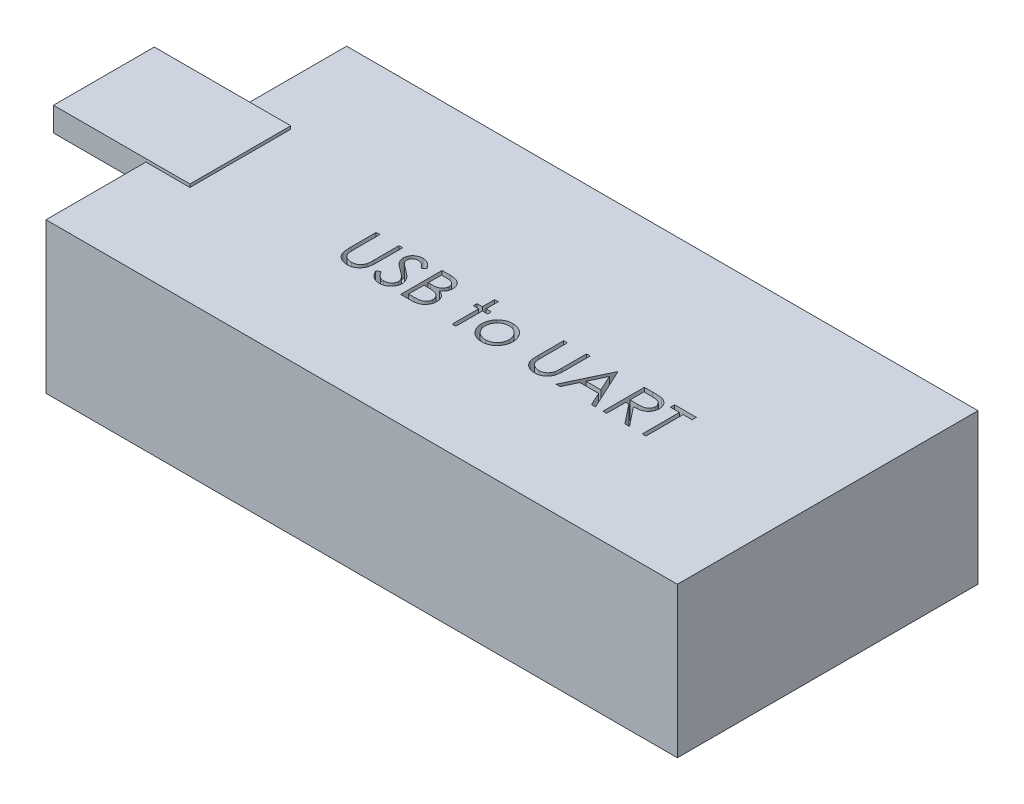
from build123d import *

# Parameters (mm, degrees)
SKETCH1_W           = 53.34
SKETCH1_H           = 25.4
BOSS_EXTRUDE1_DEPTH = 12.7
CUT_EXTRUDE1_DEPTH  = 1.524
SKETCH7_W           = 11.527903952
SKETCH7_H           = 8.5161628
BOSS_EXTRUDE4_DEPTH = 0.254
SKETCH7_3_W         = 11.527903952
SKETCH7_3_H         = 8.5161628
BOSS_EXTRUDE5_DEPTH = 1.778


with BuildPart() as part:
    # Sketch1 → Boss-Extrude1 (new body)
    with BuildSketch(Plane(origin=(0, 0, 0), x_dir=(1, 0, 0), z_dir=(0, 1, 0))):
        Rectangle(SKETCH1_W, SKETCH1_H)
    extrude(amount=BOSS_EXTRUDE1_DEPTH)

    # Sketch2 → Cut-Extrude1 (cut)
    # profile 1 of 9: a face of its own
    with BuildSketch(Plane(origin=(0, 12.7, 0), x_dir=(1, 0, 0), z_dir=(0, 1, 0))):
        with BuildLine():
            Line((-11.793928984, 0.317756753), (-11.47982642, 0.317756753))
            Line((-11.47982642, 0.317756753), (-11.47982642, -1.779298535))
            add(Edge.make_bspline(
                [(-11.47982642, -1.779298535), (-11.479873164, -1.808979271), (-11.479961869, -1.865303582), (-11.479369355, -1.945471882), (-11.477709987, -2.016744341), (-11.476663827, -2.079395689), (-11.474336494, -2.133138436), (-11.472438447, -2.178263747), (-11.46999789, -2.214557949), (-11.467064773, -2.235738875), (-11.465803984, -2.244843407)],
                knots=[0, 0, 0, 0, 1.528628734, 2.90083645, 4.128790002, 5.200304208, 6.127813768, 6.898992206, 7.526736466, 8, 8, 8, 8], degree=3))
            add(Edge.make_bspline(
                [(-11.465803984, -2.244843407), (-11.460626526, -2.27769017), (-11.450563339, -2.341532899), (-11.424916962, -2.432441181), (-11.389099461, -2.514372639), (-11.346656418, -2.589883931), (-11.290723806, -2.656873291), (-11.223720271, -2.718584943), (-11.142542503, -2.772556748), (-11.052281897, -2.82190756), (-10.954996659, -2.861572642), (-10.855585393, -2.891566007), (-10.755542414, -2.909844906), (-10.688566249, -2.911961445), (-10.65530719, -2.913012477)],
                knots=[0, 0, 0, 0, 1.035780045, 2.013197591, 2.933192213, 3.817615948, 4.702609284, 5.640816605, 6.646850145, 7.73207398, 8.84249596, 9.914020372, 10.964143139, 12, 12, 12, 12], degree=3))
            add(Edge.make_bspline(
                [(-10.65530719, -2.913012477), (-10.626753449, -2.911938627), (-10.569810887, -2.909797129), (-10.485204457, -2.896535698), (-10.402804348, -2.872635132), (-10.322203668, -2.841795374), (-10.246652684, -2.801047783), (-10.176109242, -2.753976943), (-10.113145307, -2.698766067), (-10.05568731, -2.637665722), (-10.005652374, -2.568725923), (-9.962281232, -2.493447784), (-9.926755302, -2.410698438), (-9.909211778, -2.352544015), (-9.900199017, -2.322667926)],
                knots=[0, 0, 0, 0, 0.994687771, 1.983630487, 2.973142513, 3.978332533, 4.983357753, 5.956394766, 6.925816176, 7.893390482, 8.871859704, 9.88551698, 10.913711441, 12, 12, 12, 12], degree=3))
            add(Edge.make_bspline(
                [(-9.900199017, -2.322667926), (-9.897198891, -2.310319352), (-9.890513403, -2.282801752), (-9.884266358, -2.236280461), (-9.877759833, -2.181391097), (-9.873245263, -2.117739284), (-9.868844042, -2.045538312), (-9.866210969, -1.964412054), (-9.864993936, -1.874655093), (-9.864631256, -1.812017932), (-9.864441805, -1.779298535)],
                knots=[0, 0, 0, 0, 0.558680831, 1.244966039, 2.062412453, 2.990489873, 4.051219941, 5.244515665, 6.560634259, 8, 8, 8, 8], degree=3))
            Line((-9.864441805, -1.779298535), (-9.864441805, 0.317756753))
            Line((-9.864441805, 0.317756753), (-9.550339241, 0.317756753))
            Line((-9.550339241, 0.317756753), (-9.550339241, -1.796125458))
            add(Edge.make_bspline(
                [(-9.550339241, -1.796125458), (-9.550593361, -1.834223837), (-9.551089293, -1.90857514), (-9.555389869, -2.017526499), (-9.562246869, -2.12087948), (-9.571934957, -2.218647977), (-9.58477196, -2.310482136), (-9.599047181, -2.397186904), (-9.617226714, -2.478139897), (-9.638460115, -2.553972315), (-9.662733663, -2.626157828), (-9.694174811, -2.694666443), (-9.729599311, -2.761580842), (-9.771613964, -2.825888951), (-9.818825347, -2.887875504), (-9.872277027, -2.947164579), (-9.930201188, -3.004703626), (-9.993560748, -3.059016692), (-10.061311273, -3.108825369), (-10.133251231, -3.15262314), (-10.208828001, -3.189646757), (-10.287845127, -3.220122682), (-10.37033633, -3.243037281), (-10.456303689, -3.260112436), (-10.545942883, -3.269814734), (-10.606907539, -3.271256664), (-10.637779145, -3.271986836)],
                knots=[0, 0, 0, 0, 1.316592851, 2.569410997, 3.76748051, 4.895814652, 5.963796859, 6.97159953, 7.931736103, 8.829262218, 9.692595152, 10.560224239, 11.431080259, 12.30701507, 13.211635791, 14.121146779, 15.063487852, 16.031507147, 17.00238618, 17.966455255, 18.938106653, 19.907068911, 20.888905087, 21.893141452, 22.933117798, 24, 24, 24, 24], degree=3))
            add(Edge.make_bspline(
                [(-10.637779145, -3.271986836), (-10.671448247, -3.271202071), (-10.737506906, -3.269662364), (-10.834844973, -3.260839614), (-10.92815917, -3.24422122), (-11.018435047, -3.223061276), (-11.104443544, -3.193877539), (-11.187336988, -3.159779414), (-11.265695669, -3.117902154), (-11.340790798, -3.071308761), (-11.410615554, -3.018884123), (-11.474712957, -2.961743949), (-11.533188828, -2.900803571), (-11.585057524, -2.835403205), (-11.631178409, -2.766051498), (-11.670908622, -2.692552259), (-11.705021866, -2.614933943), (-11.722628433, -2.560980742), (-11.731529145, -2.533705586)],
                knots=[0, 0, 0, 0, 1.13879206, 2.234305948, 3.301075583, 4.341971843, 5.366689343, 6.369221514, 7.369726634, 8.367512178, 9.355451585, 10.318319045, 11.268648973, 12.207971039, 13.137398894, 14.081662264, 15.030215811, 16, 16, 16, 16], degree=3))
            add(Edge.make_bspline(
                [(-11.731529145, -2.533705586), (-11.736706303, -2.515073012), (-11.747935674, -2.474658543), (-11.759960972, -2.407772054), (-11.770070054, -2.330757137), (-11.779575612, -2.243608518), (-11.78518457, -2.146258652), (-11.790102008, -2.038749736), (-11.793963627, -1.920951774), (-11.793940855, -1.838897259), (-11.793928984, -1.796125458)],
                knots=[0, 0, 0, 0, 0.625038921, 1.35572334, 2.194682327, 3.136881307, 4.189498639, 5.346923369, 6.617055217, 8, 8, 8, 8], degree=3))
            Line((-11.793928984, -1.796125458), (-11.793928984, 0.317756753))
        make_face()
    # profile 2 of 9: a face of its own
    with BuildSketch(Plane(origin=(0, 12.7, 0), x_dir=(1, 0, 0), z_dir=(0, 1, 0))):
        with BuildLine():
            Line((-9.011877702, -2.507062958), (-8.716004305, -2.329679144))
            add(Edge.make_bspline(
                [(-8.716004305, -2.329679144), (-8.688486068, -2.375743529), (-8.635762187, -2.464001113), (-8.547810828, -2.583259153), (-8.456677917, -2.68462131), (-8.361688583, -2.767497918), (-8.263422635, -2.832746804), (-8.161238581, -2.878949036), (-8.055480771, -2.907765011), (-7.983506949, -2.911265098), (-7.947574818, -2.913012477)],
                knots=[0, 0, 0, 0, 1.272034388, 2.437168799, 3.508375237, 4.49857839, 5.41946034, 6.295179144, 7.148887113, 8, 8, 8, 8], degree=3))
            add(Edge.make_bspline(
                [(-7.947574818, -2.913012477), (-7.916887957, -2.912157805), (-7.856051184, -2.910463415), (-7.766488941, -2.894182612), (-7.679507139, -2.869170484), (-7.596898501, -2.833349552), (-7.519802887, -2.790011066), (-7.452196191, -2.737664889), (-7.393750078, -2.679058683), (-7.345940964, -2.613676028), (-7.309260928, -2.54335888), (-7.28106886, -2.471182929), (-7.265423786, -2.39601436), (-7.263067033, -2.345403897), (-7.261877702, -2.319863439)],
                knots=[0, 0, 0, 0, 1.095163259, 2.171163733, 3.241058638, 4.321873601, 5.38011039, 6.391990106, 7.366004449, 8.327778327, 9.272591725, 10.192022065, 11.087607919, 12, 12, 12, 12], degree=3))
            add(Edge.make_bspline(
                [(-7.261877702, -2.319863439), (-7.263352013, -2.290722589), (-7.266349071, -2.2314835), (-7.291680551, -2.144083847), (-7.331529798, -2.057591277), (-7.368292442, -2.004090011), (-7.387378504, -1.976313759)],
                knots=[0, 0, 0, 0, 0.938893495, 1.908633276, 2.914225137, 4, 4, 4, 4], degree=3))
            add(Edge.make_bspline(
                [(-7.387378504, -1.976313759), (-7.403049118, -1.956266936), (-7.435947612, -1.914181137), (-7.492505125, -1.851535902), (-7.558871239, -1.786917483), (-7.632774794, -1.717858426), (-7.716907883, -1.647570629), (-7.808635397, -1.572702351), (-7.910299256, -1.496100774), (-7.981598753, -1.444728209), (-8.018388119, -1.418220811)],
                knots=[0, 0, 0, 0, 0.722233717, 1.516239348, 2.393582979, 3.351407094, 4.387010283, 5.505090956, 6.712668013, 8, 8, 8, 8], degree=3))
            add(Edge.make_bspline(
                [(-8.018388119, -1.418220811), (-8.055212115, -1.391992223), (-8.125616792, -1.341845161), (-8.224075374, -1.267420877), (-8.312119837, -1.199377007), (-8.389358854, -1.137072995), (-8.455758451, -1.08050039), (-8.511841862, -1.030202451), (-8.556180419, -0.98481889), (-8.580835999, -0.955377549), (-8.591905747, -0.942159112)],
                knots=[0, 0, 0, 0, 1.452282411, 2.77665338, 3.964542531, 5.026858415, 5.96415736, 6.766646006, 7.446254459, 8, 8, 8, 8], degree=3))
            add(Edge.make_bspline(
                [(-8.591905747, -0.942159112), (-8.607378293, -0.921558075), (-8.637807129, -0.881043371), (-8.677973135, -0.817718514), (-8.712112297, -0.752895248), (-8.73887463, -0.686399384), (-8.761410848, -0.619164455), (-8.776568779, -0.550313209), (-8.786060176, -0.480154591), (-8.787032163, -0.43294109), (-8.787518728, -0.409306548)],
                knots=[0, 0, 0, 0, 1.068054152, 2.10047183, 3.106115577, 4.101338837, 5.06977816, 6.043150881, 7.020423561, 8, 8, 8, 8], degree=3))
            add(Edge.make_bspline(
                [(-8.787518728, -0.409306548), (-8.786213519, -0.372276773), (-8.783630999, -0.29900871), (-8.761790482, -0.191977879), (-8.727317588, -0.089791462), (-8.6790227, 0.006538872), (-8.616765347, 0.094504853), (-8.544719373, 0.17511834), (-8.458907887, 0.242886922), (-8.364755263, 0.30209898), (-8.261698891, 0.348444906), (-8.153707988, 0.383405886), (-8.040610916, 0.403215143), (-7.964007781, 0.406057908), (-7.92513892, 0.407500343)],
                knots=[0, 0, 0, 0, 1.005424448, 1.989358655, 2.955360095, 3.929531133, 4.905563448, 5.876582895, 6.856512386, 7.866279853, 8.892233794, 9.918561126, 10.94386622, 12, 12, 12, 12], degree=3))
            add(Edge.make_bspline(
                [(-7.92513892, 0.407500343), (-7.88389482, 0.406077792), (-7.801873468, 0.403248791), (-7.681224253, 0.378651259), (-7.565063536, 0.337950587), (-7.471620272, 0.291761929), (-7.39848751, 0.245630514), (-7.342714777, 0.203610689), (-7.286197327, 0.155235581), (-7.228479272, 0.100376335), (-7.170538612, 0.038529584), (-7.11151516, -0.029881105), (-7.051270891, -0.104437661), (-7.012515031, -0.157662162), (-6.992646933, -0.184947573)],
                knots=[0, 0, 0, 0, 1.286793592, 2.559021753, 3.825965368, 5.121522368, 5.803751409, 6.523245864, 7.299691795, 8.125521123, 9.008227632, 9.944561021, 10.946284179, 12, 12, 12, 12], degree=3))
            Line((-6.992646933, -0.184947573), (-7.27660126, -0.400191964))
            add(Edge.make_bspline(
                [(-7.27660126, -0.400191964), (-7.293747193, -0.378103274), (-7.32676625, -0.335565621), (-7.376895737, -0.275994305), (-7.424144384, -0.221577826), (-7.470694784, -0.174312698), (-7.514088416, -0.131610564), (-7.556205458, -0.095050808), (-7.596439809, -0.064275212), (-7.64715672, -0.031431652), (-7.710874438, 0.001124851), (-7.790858974, 0.02867393), (-7.874445249, 0.045228991), (-7.931374881, 0.047417879), (-7.96019501, 0.048525984)],
                knots=[0, 0, 0, 0, 1.181633172, 2.275549214, 3.290209073, 4.226197932, 5.078386478, 5.862611352, 6.581680152, 7.217281963, 8.414376989, 9.595101626, 10.782541182, 12, 12, 12, 12], degree=3))
            add(Edge.make_bspline(
                [(-7.96019501, 0.048525984), (-7.996351533, 0.047314284), (-8.06607598, 0.044977635), (-8.165066216, 0.01945765), (-8.254160141, -0.020724211), (-8.330712706, -0.077039189), (-8.394449683, -0.143760181), (-8.440555142, -0.220539036), (-8.468305307, -0.305321439), (-8.471691586, -0.364463095), (-8.473416164, -0.39458299)],
                knots=[0, 0, 0, 0, 1.14458467, 2.207223713, 3.21896685, 4.227309161, 5.202851033, 6.127160689, 7.046193047, 8, 8, 8, 8], degree=3))
            add(Edge.make_bspline(
                [(-8.473416164, -0.39458299), (-8.473023037, -0.413334469), (-8.472236141, -0.450868088), (-8.461261344, -0.50631951), (-8.447162015, -0.561630849), (-8.424819383, -0.616553432), (-8.393974079, -0.672047791), (-8.353468903, -0.729069529), (-8.302455591, -0.788121238), (-8.263378579, -0.826528611), (-8.242747093, -0.846806548)],
                knots=[0, 0, 0, 0, 0.858281714, 1.717966888, 2.583508476, 3.4729293, 4.427298488, 5.488583878, 6.674047936, 8, 8, 8, 8], degree=3))
            add(Edge.make_bspline(
                [(-8.242747093, -0.846806548), (-8.235085721, -0.853643574), (-8.216884054, -0.869886782), (-8.183608128, -0.896479063), (-8.13966533, -0.929281835), (-8.086203129, -0.969869151), (-8.022235767, -1.016950614), (-7.947756211, -1.069924226), (-7.863594678, -1.130509685), (-7.803872762, -1.172867225), (-7.772294369, -1.19526408)],
                knots=[0, 0, 0, 0, 0.420754252, 0.999615792, 1.744751191, 2.668019286, 3.750313428, 4.999500688, 6.413464383, 8, 8, 8, 8], degree=3))
            add(Edge.make_bspline(
                [(-7.772294369, -1.19526408), (-7.734308456, -1.222905439), (-7.660753999, -1.276429101), (-7.556096419, -1.356844781), (-7.461202611, -1.43549255), (-7.375739408, -1.511870157), (-7.298862499, -1.58539825), (-7.231424779, -1.65696143), (-7.172739098, -1.726047003), (-7.10955988, -1.814619579), (-7.04500206, -1.923400663), (-6.989560553, -2.056678901), (-6.954602205, -2.190475222), (-6.95003069, -2.280402058), (-6.947775138, -2.324771291)],
                knots=[0, 0, 0, 0, 1.163667725, 2.253281268, 3.268753668, 4.215851969, 5.092017293, 5.902905408, 6.650798638, 7.335211899, 8.59617414, 9.77448103, 10.901945474, 12, 12, 12, 12], degree=3))
            add(Edge.make_bspline(
                [(-6.947775138, -2.324771291), (-6.948432276, -2.356149657), (-6.949733791, -2.41829704), (-6.964694705, -2.509552117), (-6.98661437, -2.598182987), (-7.019651604, -2.683094099), (-7.059974763, -2.765838862), (-7.111141011, -2.844246762), (-7.170448695, -2.920053161), (-7.23848246, -2.991236652), (-7.312928362, -3.056582848), (-7.391612057, -3.11471191), (-7.47466233, -3.163180233), (-7.561628647, -3.202731075), (-7.652530983, -3.233664593), (-7.747338767, -3.256077462), (-7.846208279, -3.269833173), (-7.91340876, -3.271260934), (-7.947574818, -3.271986836)],
                knots=[0, 0, 0, 0, 0.983748083, 1.948392443, 2.894712957, 3.844097841, 4.80183111, 5.778335162, 6.776009319, 7.81870978, 8.863265674, 9.881300176, 10.883814829, 11.87499822, 12.874611388, 13.892143829, 14.928324115, 16, 16, 16, 16], degree=3))
            add(Edge.make_bspline(
                [(-7.947574818, -3.271986836), (-7.974010161, -3.271475655), (-8.026547921, -3.270459729), (-8.104257403, -3.261478449), (-8.180396992, -3.248771345), (-8.254011274, -3.228597275), (-8.326048686, -3.204120298), (-8.39619592, -3.173981966), (-8.464486974, -3.137864764), (-8.531304557, -3.09656974), (-8.596478731, -3.048511995), (-8.659398199, -2.992538499), (-8.722127385, -2.930192994), (-8.782814781, -2.85978243), (-8.842687925, -2.782444347), (-8.900566335, -2.697455164), (-8.957648053, -2.60527781), (-8.993463521, -2.540412725), (-9.011877702, -2.507062958)],
                knots=[0, 0, 0, 0, 0.915332311, 1.819136955, 2.706846663, 3.586547465, 4.459518054, 5.340707479, 6.227863349, 7.133153174, 8.059268498, 9.028702269, 10.047606654, 11.120612155, 12.245963614, 13.433783089, 14.680604001, 16, 16, 16, 16], degree=3))
        make_face()
    # profile 3 of 9: a face of its own
    with BuildSketch(Plane(origin=(0, 12.7, 0), x_dir=(1, 0, 0), z_dir=(0, 1, 0))):
        with BuildLine():
            Line((-6.22982642, 0.317756753), (-5.546933792, 0.317756753))
            add(Edge.make_bspline(
                [(-5.546933792, 0.317756753), (-5.513505314, 0.317581003), (-5.448712604, 0.317240355), (-5.354493162, 0.311957224), (-5.266244351, 0.304753554), (-5.183940579, 0.293323461), (-5.107619876, 0.279531684), (-5.037052239, 0.262829868), (-4.972462067, 0.242803254), (-4.89534933, 0.210956973), (-4.80742867, 0.163633805), (-4.712230277, 0.09370524), (-4.630826038, 0.008172777), (-4.56063972, -0.088309879), (-4.504838601, -0.194445651), (-4.464469303, -0.307704839), (-4.438911428, -0.426626581), (-4.436282994, -0.508269759), (-4.434954625, -0.549530907)],
                knots=[0, 0, 0, 0, 1.001505555, 1.941167018, 2.826882275, 3.653841531, 4.429895133, 5.150066043, 5.825578002, 6.45369114, 7.647487171, 8.808567382, 9.977351308, 11.170798116, 12.373658725, 13.556498008, 14.765093433, 16, 16, 16, 16], degree=3))
            add(Edge.make_bspline(
                [(-4.434954625, -0.549530907), (-4.436047844, -0.588183462), (-4.438196121, -0.664139379), (-4.458738881, -0.775233489), (-4.490899549, -0.880984708), (-4.535604798, -0.981007093), (-4.593706794, -1.073040706), (-4.662565113, -1.157827972), (-4.745641916, -1.231779029), (-4.807885156, -1.273121932), (-4.839501901, -1.294122253)],
                knots=[0, 0, 0, 0, 1.044552857, 2.05264487, 3.044412934, 4.028983338, 5.005914585, 5.980388656, 6.974128949, 8, 8, 8, 8], degree=3))
            add(Edge.make_bspline(
                [(-4.839501901, -1.294122253), (-4.799741474, -1.309387252), (-4.723669926, -1.338592976), (-4.618983914, -1.39022844), (-4.528789069, -1.446390551), (-4.452391923, -1.507722401), (-4.387054268, -1.573831212), (-4.330001326, -1.645686326), (-4.281319952, -1.724225084), (-4.239607029, -1.808628619), (-4.207058272, -1.898035087), (-4.182682368, -1.991605864), (-4.168714919, -2.089005419), (-4.166727278, -2.155290798), (-4.165723856, -2.188753663)],
                knots=[0, 0, 0, 0, 1.27268992, 2.434971085, 3.483601985, 4.442670788, 5.356604649, 6.2567628, 7.179492994, 8.113709626, 9.066344395, 10.018646069, 10.999752585, 12, 12, 12, 12], degree=3))
            add(Edge.make_bspline(
                [(-4.165723856, -2.188753663), (-4.166700702, -2.222920535), (-4.168622674, -2.290144813), (-4.182802646, -2.388899948), (-4.206811753, -2.483274895), (-4.239882899, -2.573880077), (-4.283045214, -2.660540212), (-4.335573178, -2.743353476), (-4.398204742, -2.821487806), (-4.468267611, -2.895811429), (-4.547529756, -2.962639217), (-4.633045511, -3.022154923), (-4.725891831, -3.071100986), (-4.824543825, -3.112217007), (-4.930108141, -3.143624206), (-5.042110749, -3.165596779), (-5.16045505, -3.180401816), (-5.241664802, -3.181619021), (-5.283311997, -3.182243247)],
                knots=[0, 0, 0, 0, 0.978564426, 1.925352924, 2.850884081, 3.763762016, 4.682927383, 5.618979971, 6.567305752, 7.547517671, 8.540179244, 9.531824382, 10.526200242, 11.540722885, 12.589160233, 13.674978461, 14.80764778, 16, 16, 16, 16], degree=3))
            Line((-5.283311997, -3.182243247), (-6.22982642, -3.182243247))
            Line((-6.22982642, -3.182243247), (-6.22982642, 0.317756753))
        make_face()
        with BuildLine():
            Line((-5.915723856, -0.041217606), (-5.915723856, -1.163012477))
            Line((-5.915723856, -1.163012477), (-5.704686196, -1.163012477))
            add(Edge.make_bspline(
                [(-5.704686196, -1.163012477), (-5.673837401, -1.162612554), (-5.614231241, -1.161839822), (-5.527911345, -1.159626304), (-5.447786327, -1.153428261), (-5.373994494, -1.147231999), (-5.30665205, -1.137157411), (-5.245908188, -1.125165288), (-5.190809591, -1.112482383), (-5.127270046, -1.090912896), (-5.055197097, -1.059035221), (-4.978363993, -1.009563385), (-4.910629523, -0.950639032), (-4.853432336, -0.88264807), (-4.806620865, -0.807781884), (-4.77410715, -0.727235004), (-4.752059866, -0.643014872), (-4.750068334, -0.585196619), (-4.74905719, -0.555841003)],
                knots=[0, 0, 0, 0, 1.156816544, 2.235205308, 3.236616184, 4.169592532, 5.011045266, 5.787822928, 6.49130361, 7.128639758, 8.301311294, 9.436451833, 10.541879658, 11.654887649, 12.756523258, 13.837046038, 14.901820046, 16, 16, 16, 16], degree=3))
            add(Edge.make_bspline(
                [(-4.74905719, -0.555841003), (-4.74958337, -0.536415231), (-4.75061553, -0.498309459), (-4.759068832, -0.442760105), (-4.773436407, -0.390516353), (-4.7918907, -0.340862242), (-4.817679389, -0.295350392), (-4.848042852, -0.252407196), (-4.884728542, -0.213495078), (-4.926485855, -0.17712558), (-4.974494478, -0.144881052), (-5.02872577, -0.116640289), (-5.089913447, -0.093899512), (-5.157026302, -0.073983359), (-5.231097389, -0.059995066), (-5.311271943, -0.048341678), (-5.398206662, -0.042408936), (-5.458351764, -0.041623573), (-5.489441805, -0.041217606)],
                knots=[0, 0, 0, 0, 0.91205012, 1.789085906, 2.630437955, 3.453916878, 4.269457761, 5.079663411, 5.91843418, 6.774407191, 7.675494373, 8.627863946, 9.638891023, 10.736472738, 11.911756761, 13.175263542, 14.539845004, 16, 16, 16, 16], degree=3))
            Line((-5.489441805, -0.041217606), (-5.915723856, -0.041217606))
        make_face(mode=Mode.SUBTRACT)
        with BuildLine():
            Line((-5.915723856, -1.521986836), (-5.915723856, -2.823268888))
            Line((-5.915723856, -2.823268888), (-5.468408151, -2.823268888))
            add(Edge.make_bspline(
                [(-5.468408151, -2.823268888), (-5.436389225, -2.82288514), (-5.374676967, -2.822145518), (-5.285575737, -2.819730963), (-5.202992633, -2.814238687), (-5.127304497, -2.805592838), (-5.057694044, -2.796214389), (-4.994996341, -2.783603108), (-4.938703148, -2.769154147), (-4.87342884, -2.746819975), (-4.799925332, -2.712123504), (-4.720714475, -2.659809278), (-4.650288257, -2.59748597), (-4.590482998, -2.525355056), (-4.54147001, -2.446923729), (-4.505814554, -2.363778379), (-4.483823698, -2.277292851), (-4.481161528, -2.218326139), (-4.47982642, -2.188753663)],
                knots=[0, 0, 0, 0, 1.160039823, 2.235823828, 3.228722157, 4.157150951, 4.99529583, 5.772374946, 6.472645482, 7.099169577, 8.269452708, 9.405989375, 10.527446681, 11.663510218, 12.788923519, 13.866172445, 14.929861265, 16, 16, 16, 16], degree=3))
            add(Edge.make_bspline(
                [(-4.47982642, -2.188753663), (-4.480102525, -2.170260323), (-4.48065028, -2.133571941), (-4.488910895, -2.079656122), (-4.500924764, -2.027430248), (-4.516456198, -1.976752508), (-4.539075665, -1.928539132), (-4.56548221, -1.881836572), (-4.596443612, -1.836583093), (-4.644687778, -1.779370839), (-4.714859763, -1.713453826), (-4.814566538, -1.648916324), (-4.927938836, -1.596868517), (-5.010166329, -1.574769041), (-5.052642927, -1.563353022)],
                knots=[0, 0, 0, 0, 0.723448775, 1.435228256, 2.130040452, 2.821711965, 3.505591119, 4.210454504, 4.921174351, 5.648778258, 7.137944449, 8.670945889, 10.280296675, 12, 12, 12, 12], degree=3))
            add(Edge.make_bspline(
                [(-5.052642927, -1.563353022), (-5.069672023, -1.559897938), (-5.106594615, -1.552406604), (-5.166802195, -1.5444989), (-5.235538064, -1.53745384), (-5.312960942, -1.532242683), (-5.399168783, -1.526856139), (-5.494345701, -1.524761318), (-5.598103016, -1.522262058), (-5.670095388, -1.522080924), (-5.707490683, -1.521986836)],
                knots=[0, 0, 0, 0, 0.634451884, 1.375622551, 2.216452059, 3.157844607, 4.20941857, 5.370758133, 6.634282058, 8, 8, 8, 8], degree=3))
            Line((-5.707490683, -1.521986836), (-5.915723856, -1.521986836))
        make_face(mode=Mode.SUBTRACT)
    # profile 4 of 9: a face of its own
    with BuildSketch(Plane(origin=(0, 12.7, 0), x_dir=(1, 0, 0), z_dir=(0, 1, 0))):
        Polygon((-1.877262318, 0.407500343), (-1.563159754, 0.407500343), (-1.563159754, -0.624550939), (-1.114441805, -0.624550939), (-1.114441805, -0.938653503), (-1.563159754, -0.938653503), (-1.563159754, -3.182243247), (-1.877262318, -3.182243247), (-1.877262318, -0.938653503), (-2.325980267, -0.938653503), (-2.325980267, -0.624550939), (-1.877262318, -0.624550939), align=None)
    # profile 5 of 9: a face of its own
    with BuildSketch(Plane(origin=(0, 12.7, 0), x_dir=(1, 0, 0), z_dir=(0, 1, 0))):
        with BuildLine():
            add(Edge.make_bspline(
                [(0.659396336, -0.579679144), (0.707387609, -0.580701035), (0.801486766, -0.582704714), (0.939294652, -0.60411968), (1.070839788, -0.636867044), (1.19662598, -0.682138606), (1.315042276, -0.742820557), (1.42781352, -0.815229848), (1.534630529, -0.901012441), (1.598653558, -0.96737051), (1.631151144, -1.001053343)],
                knots=[0, 0, 0, 0, 1.054011418, 2.066658804, 3.057071809, 4.030435133, 4.997543892, 5.974964718, 6.972108034, 8, 8, 8, 8], degree=3))
            add(Edge.make_bspline(
                [(1.631151144, -1.001053343), (1.659133098, -1.033267328), (1.714555478, -1.097071871), (1.785621197, -1.200527484), (1.846842757, -1.307667584), (1.895905718, -1.419914911), (1.934590742, -1.536289582), (1.962056438, -1.657191593), (1.978393373, -1.78235394), (1.98059634, -1.867357778), (1.981712041, -1.910408311)],
                knots=[0, 0, 0, 0, 1.025258237, 2.030674902, 3.01204498, 3.988269485, 4.97094183, 5.956517959, 6.965070386, 8, 8, 8, 8], degree=3))
            add(Edge.make_bspline(
                [(1.981712041, -1.910408311), (1.980730704, -1.953708368), (1.978791536, -2.039271302), (1.960447919, -2.165290667), (1.931916833, -2.28748549), (1.891084995, -2.405344184), (1.838726886, -2.519227011), (1.774836198, -2.628636561), (1.698964581, -2.733788694), (1.612960584, -2.833790532), (1.517908708, -2.925956747), (1.41479256, -3.006285016), (1.305638526, -3.075106541), (1.188995173, -3.130542956), (1.065927686, -3.174252657), (0.936170618, -3.204952673), (0.799925548, -3.223514357), (0.706898326, -3.22589793), (0.659396336, -3.227115041)],
                knots=[0, 0, 0, 0, 0.998656419, 1.973391657, 2.932242238, 3.890759089, 4.846373663, 5.82037756, 6.809684879, 7.83454468, 8.860553229, 9.859544525, 10.845671541, 11.83227036, 12.833544569, 13.85385346, 14.904124723, 16, 16, 16, 16], degree=3))
            add(Edge.make_bspline(
                [(0.659396336, -3.227115041), (0.611661617, -3.225893845), (0.518170757, -3.223502071), (0.381444775, -3.205024788), (0.251455156, -3.174266805), (0.128226557, -3.130399313), (0.01108171, -3.075104769), (-0.098704786, -3.006493079), (-0.201904702, -2.925932924), (-0.296976686, -2.833796987), (-0.382975292, -2.733787031), (-0.4588483, -2.628636992), (-0.522738626, -2.519226899), (-0.57509683, -2.405344214), (-0.615928643, -2.287485482), (-0.644459736, -2.16529067), (-0.66280335, -2.039271301), (-0.664742519, -1.953708368), (-0.665723856, -1.910408311)],
                knots=[0, 0, 0, 0, 1.099876186, 2.154163076, 3.173186993, 4.173200201, 5.163417411, 6.152872554, 7.150605724, 8.17532212, 9.198891216, 10.186952605, 11.159729845, 12.11414092, 13.071450619, 14.029093627, 15.002601286, 16, 16, 16, 16], degree=3))
            add(Edge.make_bspline(
                [(-0.665723856, -1.910408311), (-0.664600546, -1.867591765), (-0.662376584, -1.782822362), (-0.646056075, -1.657895302), (-0.618697519, -1.537197913), (-0.579966122, -1.421272437), (-0.530450932, -1.309517001), (-0.470089644, -1.20211217), (-0.398299011, -1.099124369), (-0.34309706, -1.035402289), (-0.315162959, -1.003156708)],
                knots=[0, 0, 0, 0, 1.031353054, 2.041901799, 3.029428768, 4.008703097, 4.981709435, 5.96992636, 6.972712378, 8, 8, 8, 8], degree=3))
            add(Edge.make_bspline(
                [(-0.315162959, -1.003156708), (-0.282714368, -0.969181769), (-0.218898504, -0.902364073), (-0.111549776, -0.816831549), (0.000944045, -0.742915475), (0.120668971, -0.683439259), (0.246351829, -0.636600741), (0.378571072, -0.604035226), (0.516846587, -0.582781871), (0.611406208, -0.580723694), (0.659396336, -0.579679144)],
                knots=[0, 0, 0, 0, 1.027980169, 2.021703884, 2.998553061, 3.971491411, 4.943284454, 5.930300938, 6.949603206, 8, 8, 8, 8], degree=3))
        make_face()
        with BuildLine():
            add(Edge.make_bspline(
                [(0.657994092, -0.893781708), (0.624056481, -0.8947463), (0.557057352, -0.896650582), (0.458437768, -0.911134487), (0.363497614, -0.934081991), (0.27205677, -0.966686047), (0.184423597, -1.008784946), (0.100514195, -1.060493306), (0.020081755, -1.121126263), (-0.055300308, -1.190588935), (-0.124482621, -1.266467929), (-0.184960597, -1.347316288), (-0.236385704, -1.431822634), (-0.279225862, -1.520074845), (-0.311133051, -1.612967259), (-0.334306073, -1.709447891), (-0.348776313, -1.809713307), (-0.350662692, -1.877874325), (-0.351621292, -1.912511676)],
                knots=[0, 0, 0, 0, 1.021534396, 2.016698045, 2.994645724, 3.958388632, 4.93408049, 5.916473867, 6.921342795, 7.962252576, 8.998418191, 10.008913653, 10.997312074, 11.973003931, 12.956656626, 13.948281152, 14.957379055, 16, 16, 16, 16], degree=3))
            add(Edge.make_bspline(
                [(-0.351621292, -1.912511676), (-0.350014469, -1.957263703), (-0.346825224, -2.046088109), (-0.320889988, -2.176899231), (-0.277503708, -2.302481083), (-0.218916428, -2.42209747), (-0.145510209, -2.532769748), (-0.059023143, -2.631441232), (0.039616558, -2.716627043), (0.149233058, -2.787307889), (0.267587376, -2.843467645), (0.392843697, -2.88326662), (0.523484391, -2.909138313), (0.612765122, -2.911709787), (0.657994092, -2.913012477)],
                knots=[0, 0, 0, 0, 1.016792936, 2.018143844, 3.017858371, 4.030088057, 5.03801393, 6.028138512, 7.003788237, 7.991172063, 8.984598303, 9.972568034, 10.972917682, 12, 12, 12, 12], degree=3))
            add(Edge.make_bspline(
                [(0.657994092, -2.913012477), (0.703220461, -2.911702197), (0.792496057, -2.90911574), (0.922955234, -2.88339692), (1.047869206, -2.84329326), (1.166100594, -2.78737105), (1.275667197, -2.716358635), (1.375016318, -2.631922258), (1.460764929, -2.532508407), (1.534098534, -2.421950878), (1.593645277, -2.302666526), (1.636828479, -2.176876053), (1.662826065, -2.046094012), (1.666006894, -1.957265681), (1.667609477, -1.912511676)],
                knots=[0, 0, 0, 0, 1.02726834, 2.027799167, 3.010890988, 4.004497153, 4.992059811, 5.971914811, 6.958719428, 7.966827853, 8.981595046, 9.981490638, 10.983022906, 12, 12, 12, 12], degree=3))
            add(Edge.make_bspline(
                [(1.667609477, -1.912511676), (1.666651207, -1.877874118), (1.664765478, -1.809712693), (1.650290514, -1.709450239), (1.627134974, -1.612958642), (1.595163357, -1.520106639), (1.552509343, -1.431594135), (1.50009255, -1.347564408), (1.439861524, -1.266187862), (1.369844403, -1.190834221), (1.294541026, -1.121099184), (1.214075987, -1.060469795), (1.130291009, -1.009012199), (1.042912426, -0.966325959), (0.951459858, -0.934378619), (0.856652729, -0.911001987), (0.758453919, -0.89671179), (0.691694876, -0.894764649), (0.657994092, -0.893781708)],
                knots=[0, 0, 0, 0, 1.042956736, 2.052379634, 3.044323526, 4.02829302, 5.004299113, 5.996692471, 7.007513377, 8.048758398, 9.090003419, 10.095195979, 11.07790575, 12.047570684, 13.018257071, 13.989683339, 14.985167495, 16, 16, 16, 16], degree=3))
        make_face(mode=Mode.SUBTRACT)
    # profile 6 of 9: a face of its own
    with BuildSketch(Plane(origin=(0, 12.7, 0), x_dir=(1, 0, 0), z_dir=(0, 1, 0))):
        with BuildLine():
            Line((4.045814605, 0.317756753), (4.359917169, 0.317756753))
            Line((4.359917169, 0.317756753), (4.359917169, -1.779298535))
            add(Edge.make_bspline(
                [(4.359917169, -1.779298535), (4.359870425, -1.808979271), (4.359781721, -1.865303582), (4.360374235, -1.945471882), (4.362033603, -2.016744341), (4.363079763, -2.079395689), (4.365407096, -2.133138436), (4.367305143, -2.178263747), (4.3697457, -2.214557949), (4.372678817, -2.235738875), (4.373939605, -2.244843407)],
                knots=[0, 0, 0, 0, 1.528628734, 2.90083645, 4.128790002, 5.200304208, 6.127813768, 6.898992206, 7.526736466, 8, 8, 8, 8], degree=3))
            add(Edge.make_bspline(
                [(4.373939605, -2.244843407), (4.379117064, -2.27769017), (4.38918025, -2.341532899), (4.414826628, -2.432441181), (4.450644129, -2.514372639), (4.493087172, -2.589883931), (4.549019783, -2.656873291), (4.616023319, -2.718584943), (4.697201087, -2.772556748), (4.787461693, -2.82190756), (4.88474693, -2.861572642), (4.984158197, -2.891566007), (5.084201176, -2.909844906), (5.151177341, -2.911961445), (5.1844364, -2.913012477)],
                knots=[0, 0, 0, 0, 1.035780045, 2.013197591, 2.933192213, 3.817615948, 4.702609284, 5.640816605, 6.646850145, 7.73207398, 8.84249596, 9.914020372, 10.964143139, 12, 12, 12, 12], degree=3))
            add(Edge.make_bspline(
                [(5.1844364, -2.913012477), (5.212990141, -2.911938627), (5.269932702, -2.909797129), (5.354539133, -2.896535698), (5.436939242, -2.872635132), (5.517539922, -2.841795374), (5.593090906, -2.801047783), (5.663634348, -2.753976943), (5.726598282, -2.698766067), (5.78405628, -2.637665722), (5.834091216, -2.568725923), (5.877462358, -2.493447784), (5.912988287, -2.410698438), (5.930531812, -2.352544015), (5.939544573, -2.322667926)],
                knots=[0, 0, 0, 0, 0.994687771, 1.983630487, 2.973142513, 3.978332533, 4.983357753, 5.956394766, 6.925816176, 7.893390482, 8.871859704, 9.88551698, 10.913711441, 12, 12, 12, 12], degree=3))
            add(Edge.make_bspline(
                [(5.939544573, -2.322667926), (5.942544699, -2.310319352), (5.949230187, -2.282801752), (5.955477232, -2.236280461), (5.961983757, -2.181391097), (5.966498327, -2.117739284), (5.970899548, -2.045538312), (5.97353262, -1.964412054), (5.974749653, -1.874655093), (5.975112334, -1.812017932), (5.975301785, -1.779298535)],
                knots=[0, 0, 0, 0, 0.558680831, 1.244966039, 2.062412453, 2.990489873, 4.051219941, 5.244515665, 6.560634259, 8, 8, 8, 8], degree=3))
            Line((5.975301785, -1.779298535), (5.975301785, 0.317756753))
            Line((5.975301785, 0.317756753), (6.289404349, 0.317756753))
            Line((6.289404349, 0.317756753), (6.289404349, -1.796125458))
            add(Edge.make_bspline(
                [(6.289404349, -1.796125458), (6.289150228, -1.834223837), (6.288654297, -1.90857514), (6.284353721, -2.017526499), (6.277496721, -2.12087948), (6.267808633, -2.218647977), (6.25497163, -2.310482136), (6.240696409, -2.397186904), (6.222516876, -2.478139897), (6.201283475, -2.553972315), (6.177009927, -2.626157828), (6.145568778, -2.694666443), (6.110144279, -2.761580842), (6.068129626, -2.825888951), (6.020918243, -2.887875504), (5.967466562, -2.947164579), (5.909542401, -3.004703626), (5.846182842, -3.059016692), (5.778432317, -3.108825369), (5.706492359, -3.15262314), (5.630915589, -3.189646757), (5.551898463, -3.220122682), (5.46940726, -3.243037281), (5.3834399, -3.260112436), (5.293800707, -3.269814734), (5.232836051, -3.271256664), (5.201964445, -3.271986836)],
                knots=[0, 0, 0, 0, 1.316592851, 2.569410997, 3.76748051, 4.895814652, 5.963796859, 6.97159953, 7.931736103, 8.829262218, 9.692595152, 10.560224239, 11.431080259, 12.30701507, 13.211635791, 14.121146779, 15.063487852, 16.031507147, 17.00238618, 17.966455255, 18.938106653, 19.907068911, 20.888905087, 21.893141452, 22.933117798, 24, 24, 24, 24], degree=3))
            add(Edge.make_bspline(
                [(5.201964445, -3.271986836), (5.168295342, -3.271202071), (5.102236684, -3.269662364), (5.004898616, -3.260839614), (4.91158442, -3.24422122), (4.821308543, -3.223061276), (4.735300046, -3.193877539), (4.652406601, -3.159779414), (4.57404792, -3.117902154), (4.498952792, -3.071308761), (4.429128036, -3.018884123), (4.365030632, -2.961743949), (4.306554762, -2.900803571), (4.254686065, -2.835403205), (4.208565181, -2.766051498), (4.168834968, -2.692552259), (4.134721723, -2.614933943), (4.117115156, -2.560980742), (4.108214445, -2.533705586)],
                knots=[0, 0, 0, 0, 1.13879206, 2.234305948, 3.301075583, 4.341971843, 5.366689343, 6.369221514, 7.369726634, 8.367512178, 9.355451585, 10.318319045, 11.268648973, 12.207971039, 13.137398894, 14.081662264, 15.030215811, 16, 16, 16, 16], degree=3))
            add(Edge.make_bspline(
                [(4.108214445, -2.533705586), (4.103037287, -2.515073012), (4.091807915, -2.474658543), (4.079782618, -2.407772054), (4.069673536, -2.330757137), (4.060167978, -2.243608518), (4.05455902, -2.146258652), (4.049641581, -2.038749736), (4.045779963, -1.920951774), (4.045802735, -1.838897259), (4.045814605, -1.796125458)],
                knots=[0, 0, 0, 0, 0.625038921, 1.35572334, 2.194682327, 3.136881307, 4.189498639, 5.346923369, 6.617055217, 8, 8, 8, 8], degree=3))
            Line((4.045814605, -1.796125458), (4.045814605, 0.317756753))
        make_face()
    # profile 7 of 9: a face of its own
    with BuildSketch(Plane(origin=(0, 12.7, 0), x_dir=(1, 0, 0), z_dir=(0, 1, 0))):
        Polygon((8.622737682, 0.317756753), (10.238122298, -3.182243247), (9.896675983, -3.182243247), (9.379248099, -2.060448375), (7.792609477, -2.060448375), (7.260458035, -3.182243247), (6.917609477, -3.182243247), (8.577865887, 0.317756753), align=None)
        Polygon((8.596796176, -0.364434753), (7.962982073, -1.701474016), (9.213783355, -1.701474016), align=None, mode=Mode.SUBTRACT)
    # profile 8 of 9: a face of its own
    with BuildSketch(Plane(origin=(0, 12.7, 0), x_dir=(1, 0, 0), z_dir=(0, 1, 0))):
        with BuildLine():
            Line((10.866327426, 0.317756753), (11.566748099, 0.317756753))
            add(Edge.make_bspline(
                [(11.566748099, 0.317756753), (11.613489227, 0.317601167), (11.703237372, 0.317302425), (11.831810642, 0.315636662), (11.948637739, 0.310862307), (12.053657578, 0.306753723), (12.146868233, 0.299261782), (12.228555524, 0.292101135), (12.298343222, 0.282727474), (12.340589073, 0.274022051), (12.359716849, 0.270080471)],
                knots=[0, 0, 0, 0, 1.410062039, 2.707475311, 3.878576406, 4.937260626, 5.877586885, 6.699081471, 7.410979367, 8, 8, 8, 8], degree=3))
            add(Edge.make_bspline(
                [(12.359716849, 0.270080471), (12.385323473, 0.263753706), (12.435990462, 0.251235142), (12.508940529, 0.224775542), (12.578454852, 0.194155917), (12.644244677, 0.158192197), (12.705980468, 0.116617417), (12.764298779, 0.070149295), (12.819464242, 0.019042089), (12.869245872, -0.037992753), (12.916184924, -0.097829262), (12.955773551, -0.162533019), (12.98990003, -0.230194547), (13.017070547, -0.301501965), (13.038948521, -0.375763736), (13.05437476, -0.453652533), (13.063625948, -0.534813508), (13.064567803, -0.590171417), (13.065045375, -0.618240843)],
                knots=[0, 0, 0, 0, 1.027469482, 2.033020251, 3.019912614, 3.986113645, 4.951240523, 5.91722682, 6.890402269, 7.87763091, 8.8651537, 9.85103654, 10.82876324, 11.815024772, 12.821070561, 13.842952187, 14.906261191, 16, 16, 16, 16], degree=3))
            add(Edge.make_bspline(
                [(13.065045375, -0.618240843), (13.063576376, -0.664875947), (13.060709981, -0.755873115), (13.033984877, -0.887933997), (12.990208357, -1.011123311), (12.929885068, -1.125285949), (12.853065592, -1.228196595), (12.760740801, -1.31858705), (12.65285919, -1.394226962), (12.552429874, -1.446679767), (12.463715674, -1.480272676), (12.390682361, -1.503909035), (12.311015384, -1.522171), (12.225478049, -1.538531132), (12.133714394, -1.550882826), (12.035944354, -1.559929421), (11.932098203, -1.565583469), (11.860759134, -1.566425474), (11.824059798, -1.566858631)],
                knots=[0, 0, 0, 0, 1.260483769, 2.459530307, 3.627416485, 4.787058657, 5.939039949, 7.08810263, 8.267026773, 9.491475466, 10.141966685, 10.831826277, 11.566392101, 12.351337768, 13.187381173, 14.07005841, 15.007169909, 16, 16, 16, 16], degree=3))
            Line((11.824059798, -1.566858631), (13.109917169, -3.182243247))
            Line((13.109917169, -3.182243247), (12.721495695, -3.182243247))
            Line((12.721495695, -3.182243247), (11.435638323, -1.566858631))
            Line((11.435638323, -1.566858631), (11.18042999, -1.566858631))
            Line((11.18042999, -1.566858631), (11.18042999, -3.182243247))
            Line((11.18042999, -3.182243247), (10.866327426, -3.182243247))
            Line((10.866327426, -3.182243247), (10.866327426, 0.317756753))
        make_face()
        with BuildLine():
            Line((11.18042999, -0.041217606), (11.18042999, -1.207884272))
            Line((11.18042999, -1.207884272), (11.82125531, -1.212792125))
            add(Edge.make_bspline(
                [(11.82125531, -1.212792125), (11.851175349, -1.212805361), (11.909168906, -1.212831018), (11.993069571, -1.208837242), (12.071189683, -1.204293923), (12.143230435, -1.197344578), (12.20922401, -1.188388506), (12.269137424, -1.177185522), (12.323068476, -1.164133459), (12.385967014, -1.143931833), (12.456203545, -1.111925815), (12.532535005, -1.065360316), (12.597537343, -1.006791197), (12.652455205, -0.939817741), (12.696584637, -0.866181492), (12.727696691, -0.786765123), (12.747439133, -0.703573525), (12.749767679, -0.646395417), (12.75094281, -0.617539721)],
                knots=[0, 0, 0, 0, 1.146690395, 2.22261258, 3.21895312, 4.145990853, 4.996080663, 5.770904154, 6.481378293, 7.121626537, 8.300444488, 9.431385265, 10.535395872, 11.636531494, 12.74115979, 13.810798291, 14.895190096, 16, 16, 16, 16], degree=3))
            add(Edge.make_bspline(
                [(12.75094281, -0.617539721), (12.749740689, -0.589393147), (12.747358524, -0.533616908), (12.727909755, -0.451960998), (12.695020374, -0.374894048), (12.650698136, -0.302729563), (12.596698981, -0.237223827), (12.533381169, -0.181176674), (12.462475973, -0.134927209), (12.396204775, -0.105372829), (12.336970563, -0.087252976), (12.285540902, -0.074501812), (12.227429425, -0.064257343), (12.162353966, -0.056049282), (12.090592335, -0.048994338), (12.011781684, -0.044242559), (11.926444904, -0.041428695), (11.867297973, -0.041289606), (11.83667999, -0.041217606)],
                knots=[0, 0, 0, 0, 1.101028733, 2.181837193, 3.264309656, 4.369019818, 5.486613113, 6.575447106, 7.666700264, 8.788928104, 9.402425223, 10.0903467, 10.862060571, 11.710948788, 12.657782767, 13.684531032, 14.801375019, 16, 16, 16, 16], degree=3))
            Line((11.83667999, -0.041217606), (11.18042999, -0.041217606))
        make_face(mode=Mode.SUBTRACT)
    # profile 9 of 9: a face of its own
    with BuildSketch(Plane(origin=(0, 12.7, 0), x_dir=(1, 0, 0), z_dir=(0, 1, 0))):
        Polygon((13.424019733, -0.041217606), (13.424019733, 0.317756753), (15.263763323, 0.317756753), (15.263763323, -0.041217606), (14.50094281, -0.041217606), (14.50094281, -3.182243247), (14.186840246, -3.182243247), (14.186840246, -0.041217606), align=None)
    extrude(amount=-CUT_EXTRUDE1_DEPTH, mode=Mode.SUBTRACT)

    # Sketch7 → Boss-Extrude4 (add)
    with BuildSketch(Plane(origin=(0, 12.7, 0), x_dir=(1, 0, 0), z_dir=(0, 1, 0))):
        with Locations((-28.714557357, 0)):
            Rectangle(SKETCH7_W, SKETCH7_H)
    extrude(amount=BOSS_EXTRUDE4_DEPTH)

    # Sketch7_3 → Boss-Extrude5 (add)
    with BuildSketch(Plane(origin=(0, 12.7, 0), x_dir=(1, 0, 0), z_dir=(0, 1, 0))):
        with Locations((-28.714557357, 0)):
            Rectangle(SKETCH7_3_W, SKETCH7_3_H)
    extrude(amount=-BOSS_EXTRUDE5_DEPTH)


solid = part.part
